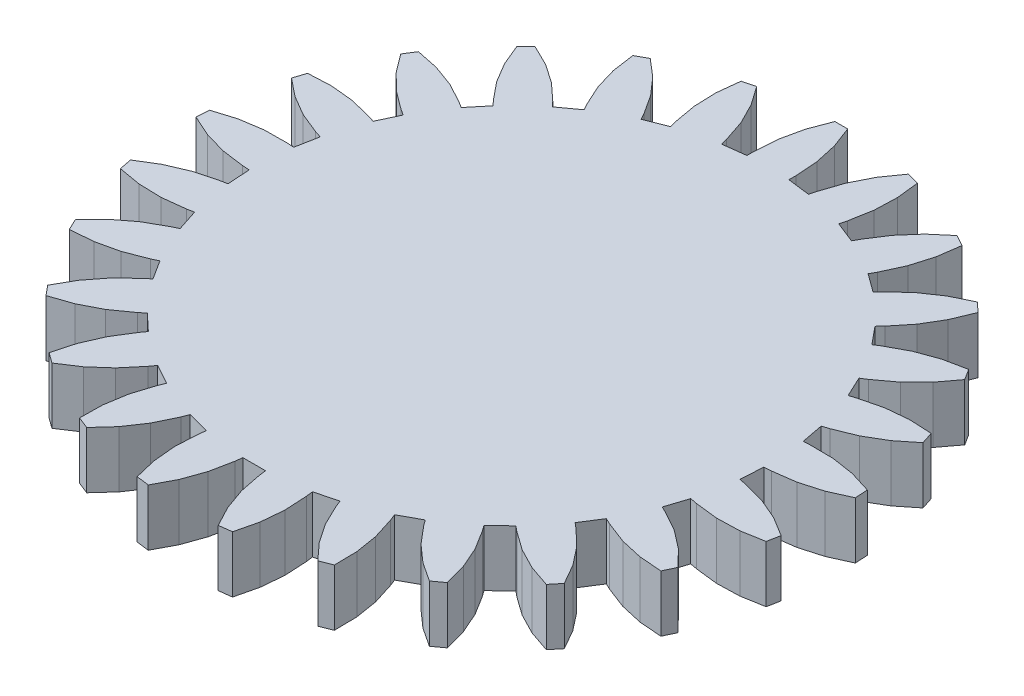
from build123d import *

# Parameters (mm, degrees)
SALIENTE_EXTRUIR1_DEPTH = 7.799999788
CORTAR_EXTRUIR1_DEPTH   = 7.400000002


with BuildPart() as part:
    # Croquis1 → Saliente-Extruir1 (new body)
    with BuildSketch(Plane.XZ):
        Polygon((59.972926974, 13.099562377), (60.438387096, 12.252889574), (62.148615718, 9.612940252), (64.220882952, 7.246527821), (66.612072289, 5.202896893), (68.158768117, 6.053198129), (67.714527249, 9.16717574), (66.826879978, 12.184839696), (65.514288843, 15.043389052), (65.048828721, 15.890061855), (67.574813962, 17.725300044), (68.236216903, 17.020983621), (70.549242198, 14.889288694), (73.14491272, 13.112574816), (75.969204307, 11.727809906), (77.25584507, 12.936044484), (76.051145792, 15.8417169), (74.440926313, 18.543824553), (72.458669543, 20.986137912), (71.797281504, 21.690456197), (73.787495494, 24.096224457), (74.603281915, 23.578517139), (77.373765409, 22.08902128), (80.329731107, 21.01364173), (83.409681916, 20.374758169), (84.355421364, 21.865004674), (82.465961576, 24.379795417), (80.234341323, 26.5965648), (77.706985176, 28.469182551), (76.891213655, 28.986889869), (78.220620751, 31.812027097), (79.139515758, 31.51345998), (82.193382084, 30.759749934), (85.323929787, 30.453277752), (88.465996087, 30.60041368), (89.011408389, 32.279040664), (86.555913091, 34.244932234), (83.843111992, 35.837076604), (80.929458141, 37.022337317), (80.010563135, 37.320904434), (80.595627427, 40.387894958), (81.559896469, 40.327228606), (84.705270827, 40.356662124), (87.813675404, 40.838353336), (90.820431709, 41.762266308), (90.931259096, 43.523795903), (88.064007461, 44.817272574), (85.040479898, 45.684751123), (81.923604012, 46.108175069), (80.959327519, 46.168841422), (80.763272941, 49.28497225), (81.712350249, 49.466017634), (84.751576185, 50.276752561), (87.642535567, 51.516339183), (90.325064957, 53.158976138), (89.994333684, 54.892722517), (86.895488203, 55.432505906), (83.751223981, 55.520810187), (80.62697202, 55.155795068), (79.677894711, 54.974749684), (78.713051975, 57.944230735), (79.58728075, 58.355610818), (82.329407334, 59.896700084), (84.821268916, 61.816297472), (87.011016905, 64.074441791), (86.259506643, 65.671473742), (83.123780787, 65.423645079), (80.056332052, 64.72722441), (77.121011913, 63.596710563), (76.246783137, 63.185326755), (74.573770165, 65.821573138), (75.318232179, 66.43743813), (77.590949833, 68.61205399), (79.527147114, 71.091033518), (81.08650893, 73.822803795), (79.961456358, 75.182773173), (76.985873282, 74.162907898), (74.187986553, 72.725526989), (71.626029909, 70.900544524), (70.881567895, 70.284672081), (68.605512381, 72.422027588), (69.173425436, 73.20369035), (70.833936334, 75.87518543), (72.092801332, 78.757800162), (72.923824191, 81.791549921), (71.495898068, 82.828991115), (68.867430091, 81.101171672), (66.514909267, 79.01314646), (64.487285912, 76.608359814), (63.919380307, 75.826704502), (61.183296144, 77.330879867), (61.538971961, 78.229218721), (62.482949346, 81.229738891), (62.985382974, 84.334857762), (63.035830855, 87.479956448), (61.394762248, 88.12969923), (59.278562665, 85.802488029), (57.519227266, 83.195015788), (56.153353304, 80.361530185), (55.797681212, 79.463198781), (52.773479372, 80.239675939), (52.894573659, 81.198245287), (53.06269601, 84.339253604), (52.777133882, 87.47176826), (52.043840289, 90.530611575), (50.292745233, 90.751826763), (48.821784556, 87.971448898), (47.766171396, 85.008360445), (47.147873789, 81.92422241), (47.026775777, 80.965660512), (43.904483318, 80.965660512), (43.783385307, 81.92422241), (43.1650877, 85.008360445), (42.10947454, 87.971448898), (40.638513863, 90.751826763), (38.887418807, 90.530611575), (38.154125214, 87.47176826), (37.868563086, 84.339253604), (38.036685437, 81.198245287), (38.157779723, 80.239675939), (35.133577883, 79.463198781), (34.777905792, 80.361530185), (33.412031829, 83.195015788), (31.652692705, 85.802488029), (29.536494985, 88.12969923), (27.895430103, 87.479956448), (27.945874259, 84.334857762), (28.448311612, 81.229738891), (29.392287135, 78.229218721), (29.747962952, 77.330879867), (27.011875063, 75.826704502), (26.443967596, 76.608359814), (24.416351691, 79.01314646), (22.063830867, 81.101171672), (19.43536289, 82.828991115), (18.00743863, 81.791549921), (18.838454038, 78.757800162), (20.097317174, 75.87518543), (21.757835522, 73.20369035), (22.325744852, 72.422027588), (20.049689338, 70.284672081), (19.305232912, 70.900544524), (16.743272543, 72.725526989), (13.945389539, 74.162907898), (10.969806463, 75.182773173), (9.844746441, 73.822803795), (11.404115707, 71.091033518), (13.340309262, 68.61205399), (15.613032505, 66.43743813), (16.35748893, 65.821573138), (14.684479684, 63.185326755), (13.810250908, 63.596710563), (10.874923319, 64.72722441), (7.807478309, 65.423645079), (4.671752453, 65.671473742), (3.920245916, 64.074441791), (6.10999018, 61.816297472), (8.601851761, 59.896700084), (11.343978345, 58.355610818), (12.218207121, 57.944230735), (11.253364384, 54.974749684), (10.304294527, 55.155795068), (7.18003884, 55.520810187), (4.035770893, 55.432505906), (0.936925411, 54.892722517), (0.606194139, 53.158976138), (3.288723528, 51.516339183), (6.17968291, 50.276752561), (9.218912572, 49.466017634), (10.167982429, 49.28497225), (9.971931577, 46.168841422), (9.007655084, 46.108175069), (5.890775472, 45.684751123), (2.867251635, 44.817272574), (0, 43.523795903), (0.110827386, 41.762266308), (3.117583692, 40.838353336), (6.225991994, 40.356662124), (9.371358901, 40.327228606), (10.335635394, 40.387894958), (10.920695961, 37.320904434), (10.001800954, 37.022337317), (7.088147104, 35.837076604), (4.375346005, 34.244932234), (1.919850707, 32.279040664), (2.465266734, 30.60041368), (5.607329309, 30.453277752), (8.737873286, 30.759749934), (11.791743338, 31.51345998), (12.710638344, 31.812027097), (14.040049165, 28.986889869), (13.22427392, 28.469182551), (10.696917772, 26.5965648), (8.465293795, 24.379795417), (6.575837731, 21.865004674), (7.521577179, 20.374758169), (10.601520538, 21.01364173), (13.557492755, 22.08902128), (16.327982768, 23.578517139), (17.143758014, 24.096224457), (19.13398318, 21.690456197), (18.472585827, 20.986137912), (16.490334645, 18.543824553), (14.880109578, 15.8417169), (13.675417751, 12.936044484), (14.962054789, 11.727809906), (17.786350101, 13.112574816), (20.382020622, 14.889288694), (22.695047781, 17.020983621), (23.356445134, 17.725300044), (25.8824341, 15.890061855), (25.416972116, 15.043389052), (24.104375392, 12.184839696), (23.216724396, 9.16717574), (22.772492841, 6.053198129), (24.319183081, 5.202896893), (26.710372418, 7.246527821), (28.782641515, 9.612940252), (30.492870137, 12.252889574), (30.958333984, 13.099562377), (33.861365169, 11.950168759), (33.621091396, 11.014342308), (33.06062147, 7.919169962), (32.951321453, 4.775561392), (33.295460045, 1.648936421), (35.00502184, 1.209996757), (36.812853068, 3.784086555), (38.23151812, 6.591510028), (39.231486619, 9.57383588), (39.471767843, 10.509666055), (42.569443583, 10.118335485), (42.569443583, 9.15215537), (42.796321213, 6.014838815), (43.472237885, 2.942811698), (44.583126903, 0), (46.348132193, 0), (47.459021211, 2.942811698), (48.134937882, 6.014838815), (48.361815512, 9.15215537), (48.361815512, 10.118335485), (51.459491253, 10.509666055), (51.699772477, 9.57383588), (52.699740976, 6.591510028), (54.118406028, 3.784086555), (55.926237255, 1.209996757), (57.63579905, 1.648936421), (57.979937643, 4.775561392), (57.870637625, 7.919169962), (57.3101677, 11.014342308), (57.069893926, 11.950168759), align=None)
    extrude(amount=-SALIENTE_EXTRUIR1_DEPTH)

    # Croquis2 → Cortar-Extruir1 (cut)
    with BuildSketch(Plane.XZ):
        Polygon((63.669033349, 47.675564885), (63.240632415, 47.97590524), (50.238601863, 50.148874521), (48.065632582, 63.150905073), (47.765284777, 63.579306006), (47.395154834, 63.949085772), (46.966463327, 64.249016345), (46.492230147, 64.470000565), (45.986838639, 64.605332911), (45.465629548, 64.650908113), (44.944424182, 64.605332911), (44.439032674, 64.470000565), (43.964799494, 64.249016345), (43.536111712, 63.949085772), (43.165974319, 63.579306006), (42.865630239, 63.150905073), (40.692660958, 50.148874521), (27.690630406, 47.97590524), (27.262229472, 47.675564885), (26.892453432, 47.305427492), (26.592519134, 46.876739711), (26.371534914, 46.402502805), (26.236202568, 45.897115022), (26.190631092, 45.375909656), (26.236202568, 44.85469684), (26.371534914, 44.349309057), (26.592519134, 43.875072151), (26.892453432, 43.44638437), (27.262229472, 43.076250702), (27.690630406, 42.775906622), (40.692660958, 40.602937341), (42.865630239, 27.600906789), (43.165974319, 27.172505856), (43.536111712, 26.802729815), (43.964799494, 26.502795517), (44.439032674, 26.281811297), (44.944424182, 26.146478951), (45.465629548, 26.100907475), (45.986838639, 26.146478951), (46.492230147, 26.281811297), (46.966463327, 26.502795517), (47.395154834, 26.802729815), (47.765284777, 27.172505856), (48.065632582, 27.600906789), (50.238601863, 40.602937341), (63.240632415, 42.775906622), (63.669033349, 43.076250702), (64.038813114, 43.44638437), (64.338743687, 43.875072151), (64.559727907, 44.349309057), (64.695060253, 44.85469684), (64.740628004, 45.375909656), (64.695060253, 45.897115022), (64.559727907, 46.402502805), (64.338743687, 46.876739711), (64.038813114, 47.305427492), align=None)
    extrude(amount=-CORTAR_EXTRUIR1_DEPTH, mode=Mode.SUBTRACT)


solid = part.part
